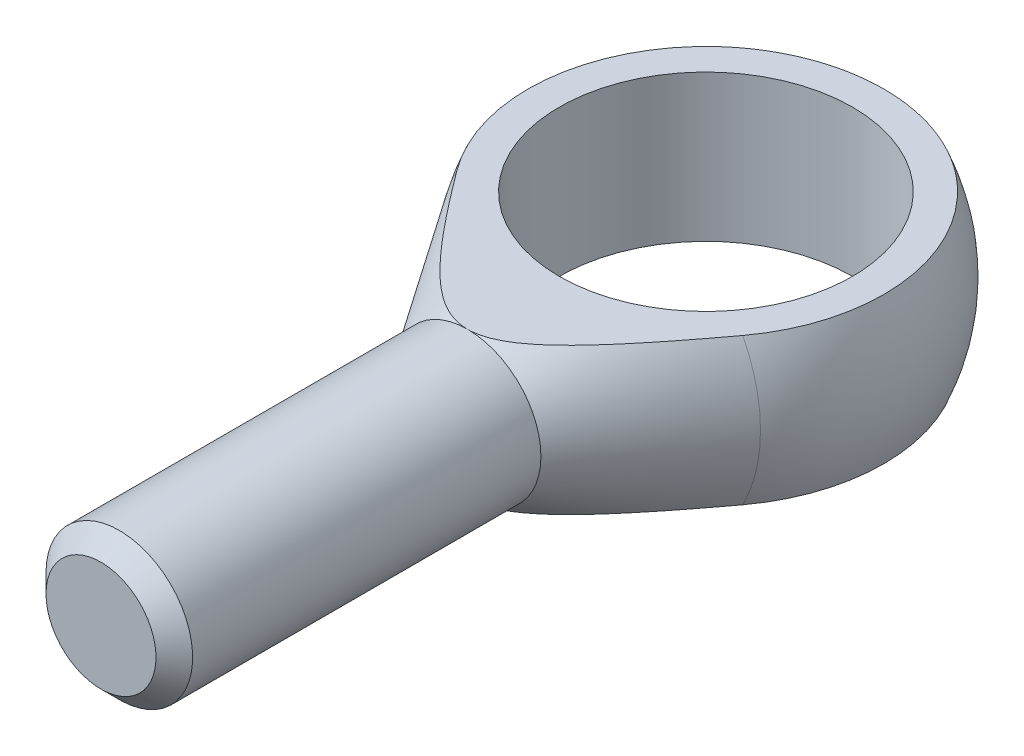
from build123d import *

# Parameters (mm, degrees)
SZKIC1_W                        = 8
SZKIC1_H                        = 40
WYTNIJ_WYCI_GNI_CIE1_DEPTH      = 22
WYTNIJ_WYCI_GNI_CIE1_DEPTH_BACK = 22
SZKIC3_R                        = 16
WYTNIJ_WYCI_GNI_CIE2_DEPTH      = 9
WYTNIJ_WYCI_GNI_CIE2_DEPTH_BACK = 9
SFAZOWANIE1_SIZE                = 2


with BuildPart() as part:
    # Szkic1 → Obrót1 (revolve)
    with BuildSketch(Plane(origin=(0, 0, 0), x_dir=(1, 0, 0), z_dir=(0, 1, 0))):
        with BuildLine():
            Line((0, 21), (0, -26))
            Line((0, -26), (8, -26))
            Line((8, -26), (17.525976473, -11.568930316))
            ThreePointArc((17.525976473, -11.568930316), (18.492532772, 9.951192475), (0, 21))
        make_face()
        with Locations((4, -46)):
            Rectangle(SZKIC1_W, SZKIC1_H)
    revolve(axis=Axis((0, 0, -26.043516498), (0, 0, 1)))

    # Szkic2 → Wytnij-wyciągnięcie1 (cut, two sides)
    with BuildSketch(Plane(origin=(0, 0, 0), x_dir=(0, 0, -1), z_dir=(1, 0, 0))) as wytnij_wyci_gni_cie1_sk:
        with BuildLine():
            Line((-26, 8), (19.416487839, 8))
            ThreePointArc((19.416487839, 8), (6.171069333, 20.072815031), (-11.568930316, 17.525976473))
            Line((-11.568930316, 17.525976473), (-26, 8))
        make_face()
        with BuildLine():
            Line((-26, -8), (19.416487839, -8))
            ThreePointArc((19.416487839, -8), (6.171069333, -20.072815031), (-11.568930316, -17.525976473))
            Line((-11.568930316, -17.525976473), (-26, -8))
        make_face()
    extrude(amount=WYTNIJ_WYCI_GNI_CIE1_DEPTH, mode=Mode.SUBTRACT)
    extrude(wytnij_wyci_gni_cie1_sk.sketch, amount=-WYTNIJ_WYCI_GNI_CIE1_DEPTH_BACK, mode=Mode.SUBTRACT)

    # Szkic3 → Wytnij-wyciągnięcie2 (cut, two sides)
    with BuildSketch(Plane(origin=(0, 0, 0), x_dir=(1, 0, 0), z_dir=(0, 1, 0))) as wytnij_wyci_gni_cie2_sk:
        Circle(SZKIC3_R)
    extrude(amount=WYTNIJ_WYCI_GNI_CIE2_DEPTH, mode=Mode.SUBTRACT)
    extrude(wytnij_wyci_gni_cie2_sk.sketch, amount=-WYTNIJ_WYCI_GNI_CIE2_DEPTH_BACK, mode=Mode.SUBTRACT)

    # Sfazowanie1
    sfazowanie1_edges = [part.edges().sort_by_distance(p)[0] for p in [
        (-8, 0, 66),
    ]]
    chamfer(sfazowanie1_edges, length=SFAZOWANIE1_SIZE)


solid = part.part
